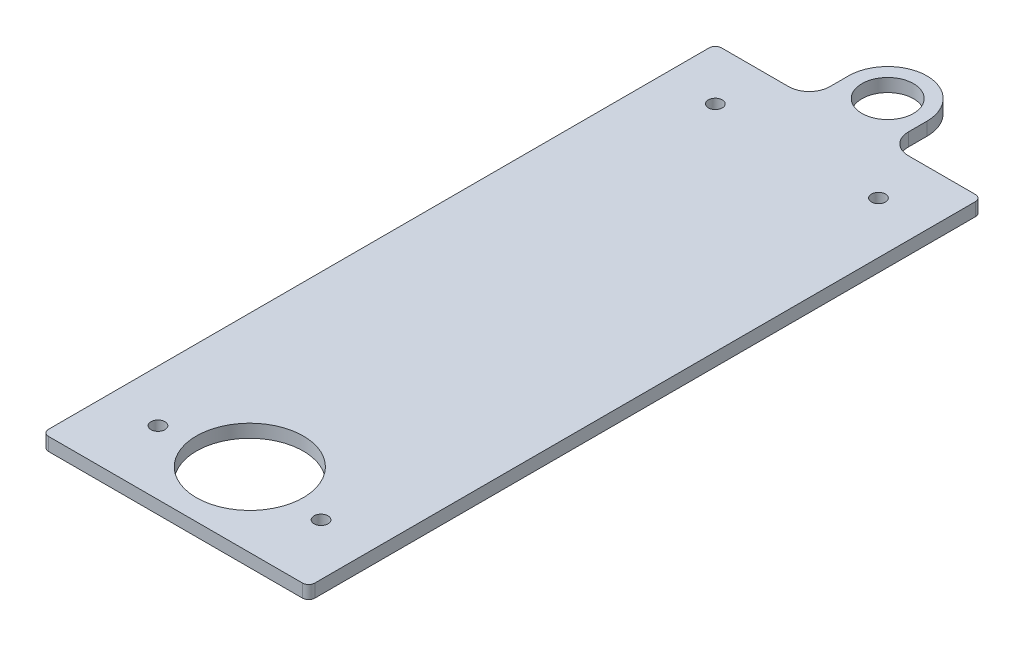
from build123d import *

# Parameters (mm, degrees)
SKETCH1_R                   = 25.9
SKETCH1_R_2                 = 12.5
BOSS_EXTRUDE1_DEPTH         = 6.35
F_1_4_CLEARANCE_HOLE1_D     = 6.7564
F_1_4_CLEARANCE_HOLE1_DEPTH = 19.53
F_1_4_CLEARANCE_HOLE1_TIP   = 2.029827343
FILLET1_R                   = 10
FILLET2_R                   = 3


with BuildPart() as part:
    # Sketch1 → Boss-Extrude1 (new body)
    with BuildSketch(Plane(origin=(0, 0, 0), x_dir=(1, 0, 0), z_dir=(0, 1, 0))):
        with BuildLine():
            Line((-64.5, 160), (-19, 160))
            Line((-19, 160), (-19, 179))
            ThreePointArc((-19, 179), (0, 198), (19, 179))
            Line((19, 179), (19, 160))
            Line((19, 160), (64.5, 160))
            Line((64.5, 160), (64.5, -166))
            Line((64.5, -166), (-64.5, -166))
            Line((-64.5, -166), (-64.5, 160))
        make_face()
        with Locations(Location((0, -130, 0), (0, 0, 270))):  # turned: the seam where the file's is
            Circle(SKETCH1_R, mode=Mode.SUBTRACT)
        with Locations(Location((0, 179, 0), (0, 0, 270))):  # turned: the seam where the file's is
            Circle(SKETCH1_R_2, mode=Mode.SUBTRACT)
    extrude(amount=BOSS_EXTRUDE1_DEPTH)

    # 1/4 Clearance Hole1
    with Locations(Plane(origin=(0, 6.35, 0), x_dir=(1, 0, 0), z_dir=(0, 1, 0))):
        with Locations((-39.5, 135), (39.5, 135), (39.5, -135), (-39.5, -135)):
            Hole(F_1_4_CLEARANCE_HOLE1_D / 2, depth=F_1_4_CLEARANCE_HOLE1_DEPTH)
            with Locations((0, 0, -(F_1_4_CLEARANCE_HOLE1_DEPTH + F_1_4_CLEARANCE_HOLE1_TIP / 2))):  # 118° drill point
                Cone(0, F_1_4_CLEARANCE_HOLE1_D / 2, F_1_4_CLEARANCE_HOLE1_TIP, mode=Mode.SUBTRACT)

    # Fillet1
    fillet1_edges = [part.edges().sort_by_distance(p)[0] for p in [
        (-19, 3.175, -160),
        (19, 3.175, -160),
    ]]
    fillet(fillet1_edges, radius=FILLET1_R)

    # Fillet2
    fillet2_edges = [part.edges().sort_by_distance(p)[0] for p in [
        (64.5, 3.175, 166),
        (-64.5, 3.175, 166),
        (-64.5, 3.175, -160),
        (64.5, 3.175, -160),
    ]]
    fillet(fillet2_edges, radius=FILLET2_R)


solid = part.part
